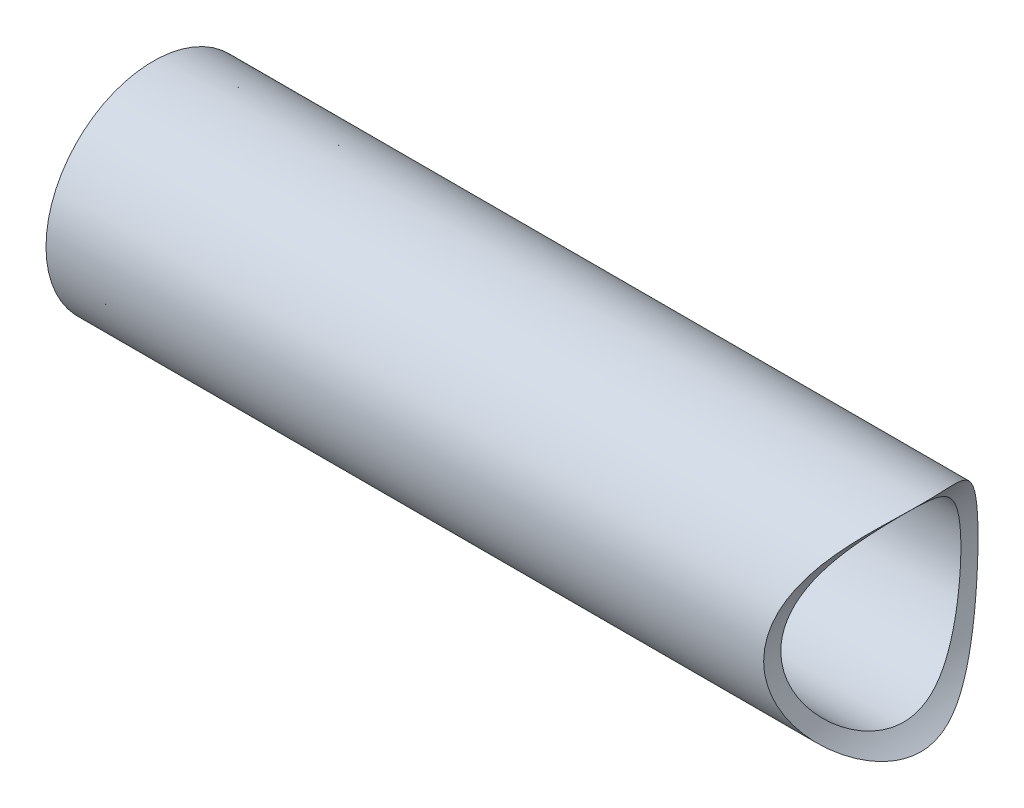
from build123d import *

# Parameters (mm, degrees)
SKETCH1_R           = 9.525
BOSS_EXTRUDE1_DEPTH = 76.2
SKETCH3_R           = 8.509
CUT_EXTRUDE1_DEPTH  = 1.524
SKETCH4_R           = 8.001
CUT_EXTRUDE2_DEPTH  = 75.676
SKETCH5_R           = 12.4206
CUT_EXTRUDE3_DEPTH  = 254


with BuildPart() as part:
    # Sketch1 → Boss-Extrude1 (new body)
    with BuildSketch(Plane(origin=(0, 0, 0), x_dir=(0, 0, -1), z_dir=(1, 0, 0))):
        Circle(SKETCH1_R)
    extrude(amount=BOSS_EXTRUDE1_DEPTH)

    # Sketch3 → Cut-Extrude1 (cut)
    with BuildSketch(Plane.ZY):
        Circle(SKETCH3_R)
    extrude(amount=-CUT_EXTRUDE1_DEPTH, mode=Mode.SUBTRACT)

    # Sketch4 → Cut-Extrude2 (cut, through all)
    with BuildSketch(Plane.ZY.offset(-1.524)):
        Circle(SKETCH4_R)
    extrude(amount=-CUT_EXTRUDE2_DEPTH, mode=Mode.SUBTRACT)

    # Sketch5 → Cut-Extrude3 (cut)
    with BuildSketch(Plane.XY.offset(9.525)):
        with Locations((76.2, 0)):
            Circle(SKETCH5_R)
    extrude(amount=-CUT_EXTRUDE3_DEPTH, mode=Mode.SUBTRACT)


solid = part.part
